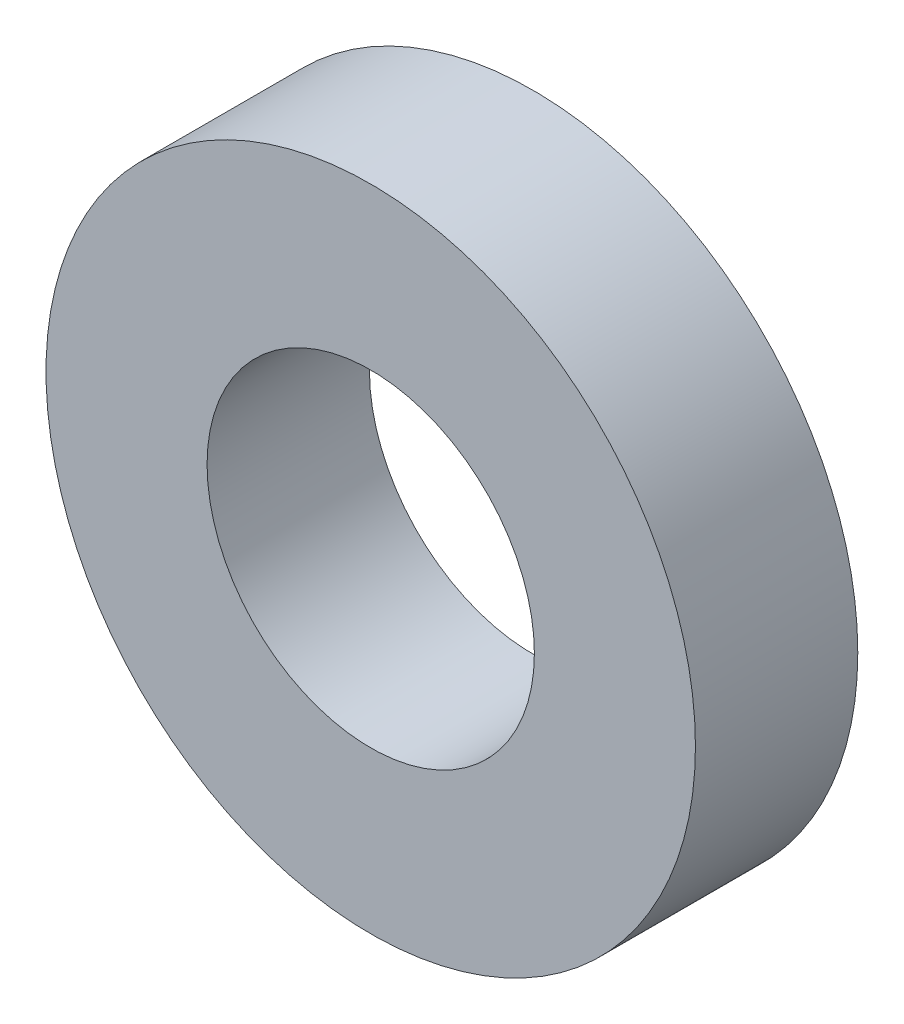
from build123d import *

# Parameters (mm, degrees)
SKETCH1_R      = 6.35
SKETCH1_R_2    = 3.2004
EXTRUDE1_DEPTH = 1.5875


with BuildPart() as part:
    # Sketch1 → Extrude1 (new body, symmetric)
    with BuildSketch(Plane.XY):
        Circle(SKETCH1_R)
        Circle(SKETCH1_R_2, mode=Mode.SUBTRACT)
    extrude(amount=EXTRUDE1_DEPTH, both=True)


solid = part.part
